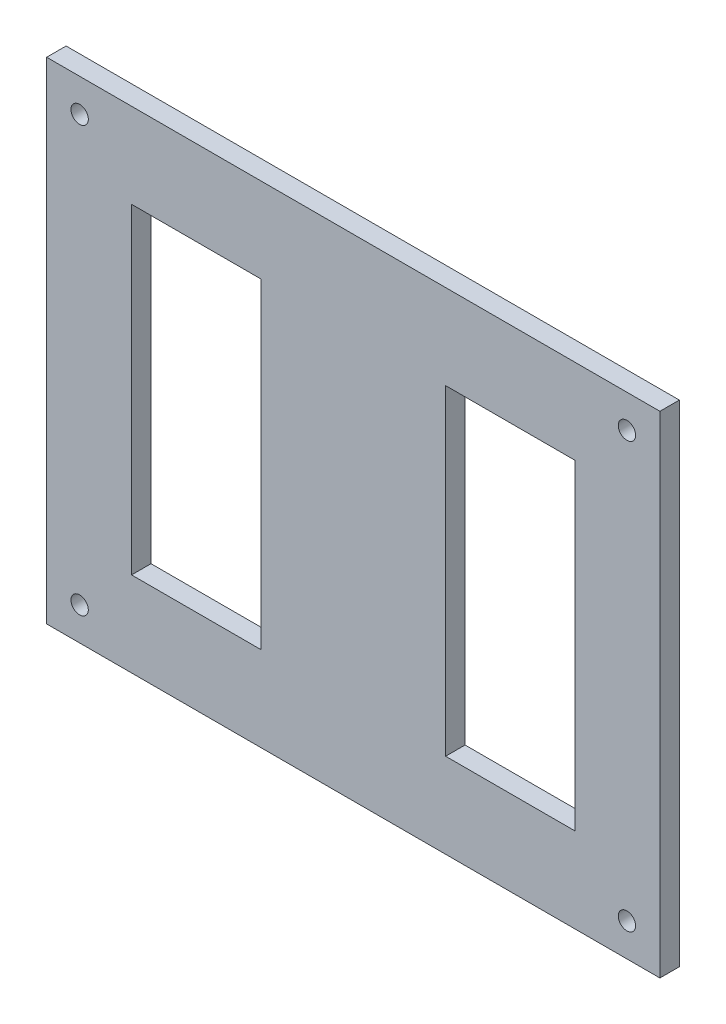
from build123d import *

# Parameters (mm, degrees)
SKETCH1_W           = 100.17
SKETCH1_H           = 80.17
BOSS_EXTRUDE1_DEPTH = 3.175
SKETCH3_R           = 1.415
CUT_EXTRUDE2_DEPTH  = 4.175
SKETCH2_W           = 21.13
SKETCH2_H           = 52.43
CUT_EXTRUDE4_DEPTH  = 10


with BuildPart() as part:
    # Sketch1 → Boss-Extrude1 (new body)
    with BuildSketch(Plane.XY):
        Rectangle(SKETCH1_W, SKETCH1_H)
    extrude(amount=BOSS_EXTRUDE1_DEPTH)

    # Sketch3 → Cut-Extrude2 (cut, through all)
    with BuildSketch(Plane.XY.offset(3.175)):
        with Locations((-44.696699141, 34.696699141)):
            Circle(SKETCH3_R)
        with Locations((44.696699141, 34.696699141)):
            Circle(SKETCH3_R)
        with Locations((44.696699141, -34.696699141)):
            Circle(SKETCH3_R)
        with Locations((-44.696699141, -34.696699141)):
            Circle(SKETCH3_R)
    extrude(amount=-CUT_EXTRUDE2_DEPTH, mode=Mode.SUBTRACT)

    # Sketch2 → Cut-Extrude4 (cut)
    with BuildSketch(Plane.XY.offset(3.175)):
        with Locations((25.65, 0)):
            Rectangle(SKETCH2_W, SKETCH2_H)
        with Locations((-25.65, 0)):
            Rectangle(SKETCH2_W, SKETCH2_H)
    extrude(amount=-CUT_EXTRUDE4_DEPTH, mode=Mode.SUBTRACT)


solid = part.part
